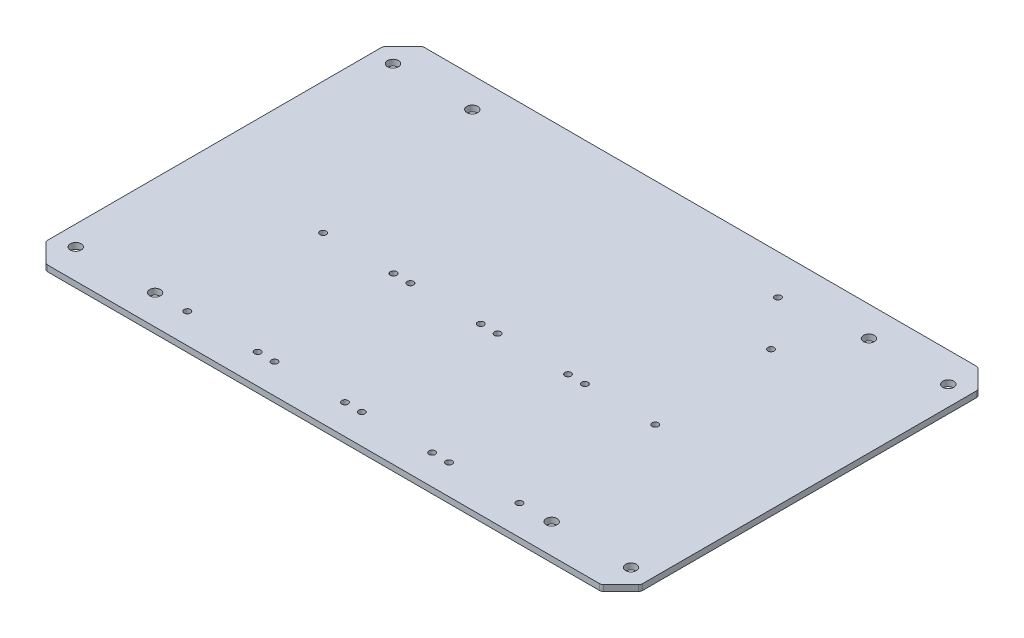
from build123d import *

# Parameters (mm, degrees)
ESQUISSE1_W                     = 300
ESQUISSE1_H                     = 190
BOSS_EXTRU_1_DEPTH              = 3
CHANFREIN1_SIZE                 = 10
CONG_1_R                        = 2
ESQUISSE2_R                     = 2.75
ENL_V_MAT_EXTRU_1_DEPTH         = 4
R_P_TITION_LIN_AIRE1_COUNT      = 2
R_P_TITION_LIN_AIRE1_PITCH      = 240
R_P_TITION_LIN_AIRE1_COUNT_DIR2 = 2
R_P_TITION_LIN_AIRE1_PITCH_DIR2 = 160
ESQUISSE3_R                     = 1.6
ENL_V_MAT_EXTRU_2_DEPTH         = 4
R_P_TITION_LIN_AIRE2_COUNT      = 4
R_P_TITION_LIN_AIRE2_PITCH      = 44
ESQUISSE4_R                     = 1.6
ESQUISSE4_R_2                   = 2.75
ENL_V_MAT_EXTRU_3_DEPTH         = 10


with BuildPart() as part:
    # Esquisse1 → Boss.-Extru.1 (new body)
    with BuildSketch(Plane(origin=(0, 0, 0), x_dir=(1, 0, 0), z_dir=(0, 1, 0))):
        Rectangle(ESQUISSE1_W, ESQUISSE1_H)
    extrude(amount=BOSS_EXTRU_1_DEPTH)

    # Chanfrein1
    chanfrein1_edges = [part.edges().sort_by_distance(p)[0] for p in [
        (150, 1.5, 95),
        (-150, 1.5, 95),
        (-150, 1.5, -95),
        (150, 1.5, -95),
    ]]
    chamfer(chanfrein1_edges, length=CHANFREIN1_SIZE)

    # Congé1
    cong_1_edges = [part.edges().sort_by_distance(p)[0] for p in [
        (140, 1.5, 95),
        (-140, 1.5, 95),
        (-150, 1.5, -85),
        (-150, 1.5, 85),
        (150, 1.5, -85),
        (150, 1.5, 85),
        (-140, 1.5, -95),
        (140, 1.5, -95),
    ]]
    fillet(cong_1_edges, radius=CONG_1_R)

    # Esquisse2 → Enlèv. mat.-Extru.1 (cut, through all)
    with BuildSketch(Plane.XZ):
        with Locations((-140, 80)):
            Circle(ESQUISSE2_R)
        with Locations((-100, 80)):
            Circle(ESQUISSE2_R)
    enl_v_mat_extru_1 = extrude(amount=-ENL_V_MAT_EXTRU_1_DEPTH, mode=Mode.SUBTRACT)

    # Répétition linéaire1: Enl_v. mat.-Extru.1 2 × 2
    with Locations(*[(i * R_P_TITION_LIN_AIRE1_PITCH, 0, -j * R_P_TITION_LIN_AIRE1_PITCH_DIR2) for i in range(R_P_TITION_LIN_AIRE1_COUNT) for j in range(R_P_TITION_LIN_AIRE1_COUNT_DIR2) if (i, j) != (0, 0)]):
        add(enl_v_mat_extru_1, mode=Mode.SUBTRACT)

    # Esquisse3 → Enlèv. mat.-Extru.2 (cut, through all)
    with BuildSketch(Plane(origin=(0, 3, 0), x_dir=(1, 0, 0), z_dir=(0, 1, 0))):
        with Locations((-83.75, -80)):
            Circle(ESQUISSE3_R)
        with Locations((-48.25, -80)):
            Circle(ESQUISSE3_R)
        with Locations((-83.75, -11.5)):
            Circle(ESQUISSE3_R)
        with Locations((-48.25, -11.5)):
            Circle(ESQUISSE3_R)
    enl_v_mat_extru_2 = extrude(amount=-ENL_V_MAT_EXTRU_2_DEPTH, mode=Mode.SUBTRACT)

    # Répétition linéaire2: Enlèv. mat.-Extru.2 ×4
    with Locations(*[(i * R_P_TITION_LIN_AIRE2_PITCH, 0, 0) for i in range(1, R_P_TITION_LIN_AIRE2_COUNT)]):
        add(enl_v_mat_extru_2, mode=Mode.SUBTRACT)

    # Esquisse4 → Enlèv. mat.-Extru.3 (cut)
    with BuildSketch(Plane(origin=(0, 3, 0), x_dir=(1, 0, 0), z_dir=(0, 1, 0))):
        with Locations((59.1, 75)):
            Circle(ESQUISSE4_R)
        with Locations((80, 50.6)):
            Circle(ESQUISSE4_R)
        with Locations((100, 80)):
            Circle(ESQUISSE4_R_2)
    extrude(amount=-ENL_V_MAT_EXTRU_3_DEPTH, mode=Mode.SUBTRACT)


solid = part.part
